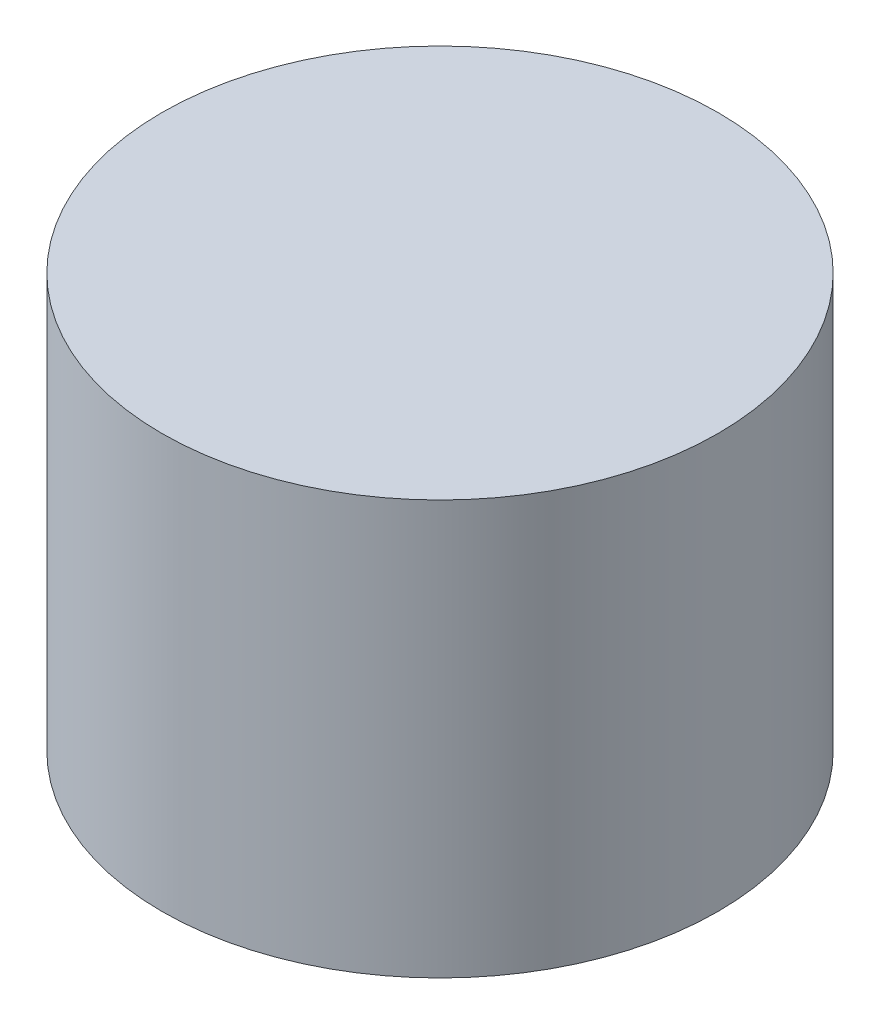
from build123d import *

# Parameters (mm, degrees)
CROQUIS1_R              = 45
CROQUIS1_R_2            = 42.8
SALIENTE_EXTRUIR1_DEPTH = 65
CROQUIS2_R              = 45
SALIENTE_EXTRUIR2_DEPTH = 2


with BuildPart() as part:
    # Croquis1 → Saliente-Extruir1 (new body)
    with BuildSketch(Plane(origin=(0, 0, 0), x_dir=(1, 0, 0), z_dir=(0, 1, 0))):
        Circle(CROQUIS1_R)
        Circle(CROQUIS1_R_2, mode=Mode.SUBTRACT)
    extrude(amount=SALIENTE_EXTRUIR1_DEPTH)

    # Croquis2 → Saliente-Extruir2 (add)
    with BuildSketch(Plane(origin=(0, 65, 0), x_dir=(1, 0, 0), z_dir=(0, 1, 0))):
        Circle(CROQUIS2_R)
    extrude(amount=SALIENTE_EXTRUIR2_DEPTH)


solid = part.part
